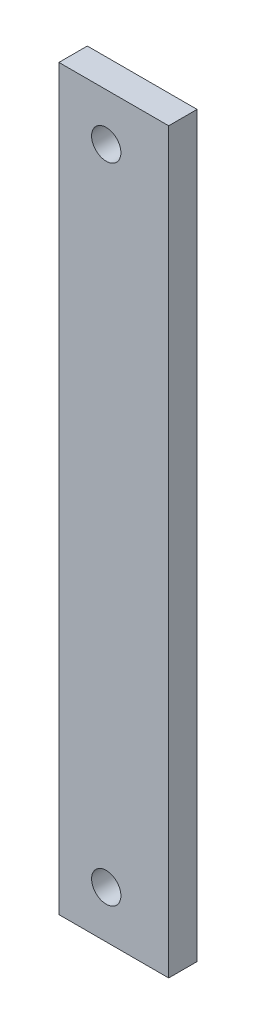
from build123d import *

# Parameters (mm, degrees)
SKETCH1_W             = 18.415
SKETCH1_H             = 123.825
BOSS_EXTRUDE1_DEPTH   = 4.7625
F_8_CLEARANCE_HOLE1_D = 4.9149


with BuildPart() as part:
    # Sketch1 → Boss-Extrude1 (new body)
    with BuildSketch(Plane.XY):
        with Locations((3007.379618147, 6363.335)):
            Rectangle(SKETCH1_W, SKETCH1_H)
    extrude(amount=BOSS_EXTRUDE1_DEPTH)

    # #8 Clearance Hole1 (through all)
    with Locations(Plane.XY.offset(4.7625)):
        with Locations((3006.109618147, 6417.31), (3006.109618147, 6309.36)):
            Hole(F_8_CLEARANCE_HOLE1_D / 2)


solid = part.part
